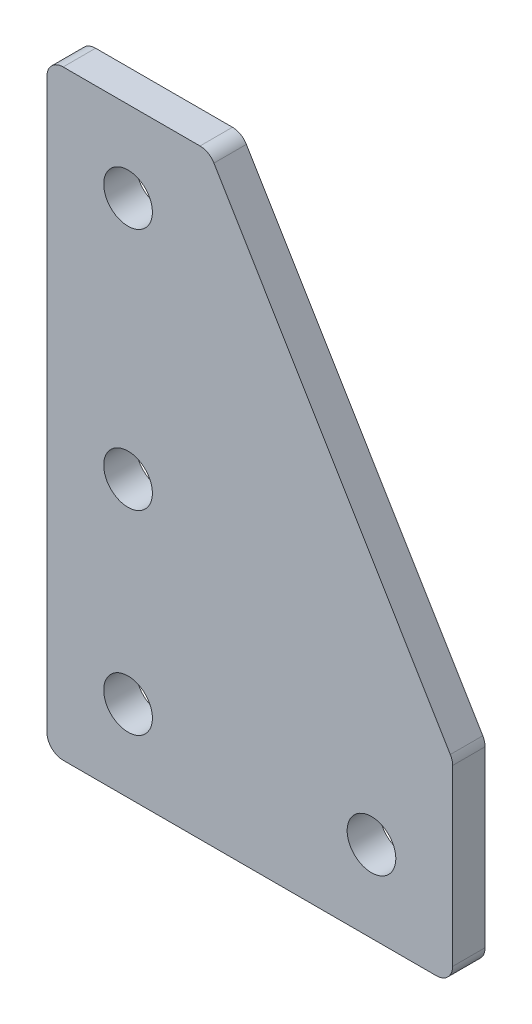
from build123d import *

# Parameters (mm, degrees)
SKETCH_1_R      = 1.5
EXTRUDE_1_DEPTH = 2
FILLET_1_R      = 1


with BuildPart() as part:
    # 草图1 → 凸台-拉伸1 (new body)
    with BuildSketch(Plane.XY):
        Polygon((-5, 32), (5, 32), (20, 7), (20, -5), (-5, -5), align=None)
        with Locations((0, 27)):
            Circle(SKETCH_1_R, mode=Mode.SUBTRACT)
        with Locations((0, 12)):
            Circle(SKETCH_1_R, mode=Mode.SUBTRACT)
        with Locations((15, 0)):
            Circle(SKETCH_1_R, mode=Mode.SUBTRACT)
        Circle(SKETCH_1_R, mode=Mode.SUBTRACT)
    extrude(amount=EXTRUDE_1_DEPTH)

    # 圆角1
    fillet_1_edges = [part.edges().sort_by_distance(p)[0] for p in [
        (-5, 32, 1),
        (5, 32, 1),
        (20, 7, 1),
        (20, -5, 1),
        (-5, -5, 1),
    ]]
    fillet(fillet_1_edges, radius=FILLET_1_R)


solid = part.part
